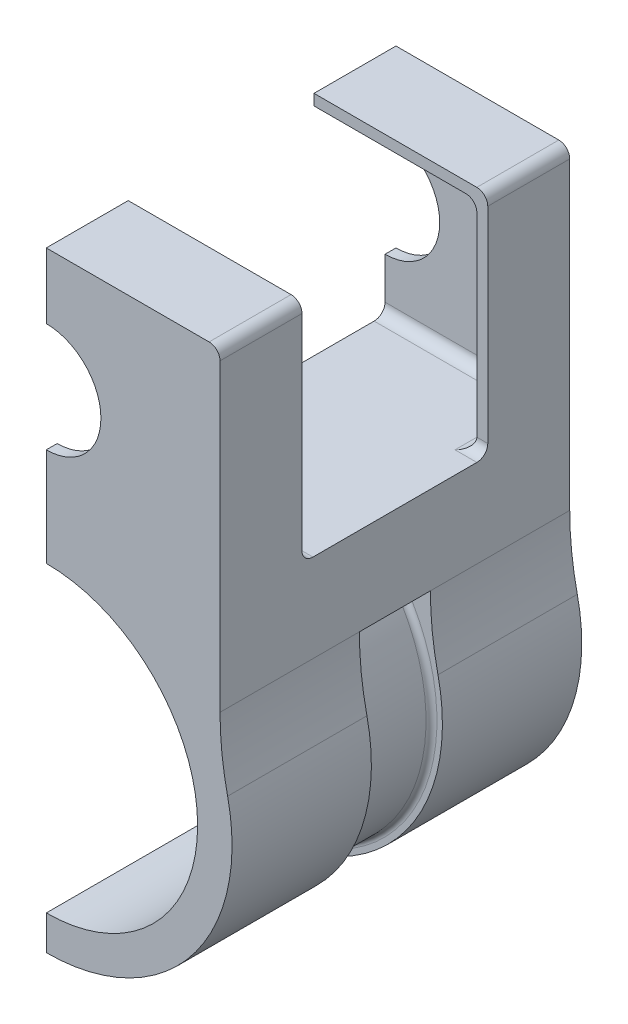
from build123d import *

# Parameters (mm, degrees)
BOSS_EXTRUDE1_DEPTH            = 81.28
SKETCH3_W                      = 76.2
SKETCH3_H                      = 50.292
CUT_EXTRUDE1_DEPTH             = 37.846
SKETCH4_W                      = 40.386
SKETCH4_H                      = 43.18
CUT_EXTRUDE2_DEPTH             = 52.832
FILLET1_R                      = 2.54
FILLET2_R                      = 2.54
FILLET3_R                      = 2.54
FILLET4_R                      = 2.54
SKETCH7_W                      = 16.51
SKETCH7_H                      = 2.54
CUT_EXTRUDE4_REACH             = 54.566
SKETCH8_W                      = 16.51
SKETCH8_H                      = 16.012242806
CUT_EXTRUDE4_DIRECTION_2_DEPTH = 2.54
FILLET5_R                      = 1.27


with BuildPart() as part:
    # Sketch1 → Boss-Extrude1 (new body)
    with BuildSketch(Plane.XY):
        with BuildLine():
            Line((0, 52.959), (0, 58.039))
            ThreePointArc((0, 58.039), (12.7, 70.739), (0, 83.439))
            Line((0, 83.439), (0, 98.679))
            Line((0, 98.679), (40.386, 98.679))
            Line((40.386, 98.679), (40.386, 25.398729968))
            ThreePointArc((40.386, 25.398729968), (40.827682914, 17.344312358), (42.147434783, 9.386487162))
            ThreePointArc((42.147434783, 9.386487162), (33.688432107, -27.011144777), (0, -43.18))
            Line((0, -43.18), (0, -35.179))
            ThreePointArc((0, -35.179), (35.179, 0), (0, 35.179))
            Line((0, 35.179), (0, 52.959))
        make_face()
    extrude(amount=-BOSS_EXTRUDE1_DEPTH)

    # Sketch3 → Cut-Extrude1 (cut)
    with BuildSketch(Plane.ZY):
        with Locations((-40.64, 70.993)):
            Rectangle(SKETCH3_W, SKETCH3_H)
    extrude(amount=-CUT_EXTRUDE1_DEPTH, mode=Mode.SUBTRACT)

    # Sketch4 → Cut-Extrude2 (cut)
    with BuildSketch(Plane(origin=(0, 98.679, 0), x_dir=(1, 0, 0), z_dir=(0, 1, 0))):
        with Locations((20.193, 40.64)):
            Rectangle(SKETCH4_W, SKETCH4_H)
    extrude(amount=-CUT_EXTRUDE2_DEPTH, mode=Mode.SUBTRACT)

    # Fillet1
    fillet1_edges = [part.edges().sort_by_distance(p)[0] for p in [
        (18.923, 45.847, -78.74),
        (18.923, 45.847, -2.54),
        (37.846, 45.847, -10.795),
        (37.846, 45.847, -70.485),
    ]]
    fillet(fillet1_edges, radius=FILLET1_R)

    # Fillet2
    fillet2_edges = [part.edges().sort_by_distance(p)[0] for p in [
        (37.846, 96.139, -70.485),
        (37.846, 96.139, -10.795),
    ]]
    fillet(fillet2_edges, radius=FILLET2_R)

    # Fillet3
    fillet3_edges = [part.edges().sort_by_distance(p)[0] for p in [
        (36.576, 45.847, -19.05),
        (36.576, 45.847, -62.23),
    ]]
    fillet(fillet3_edges, radius=FILLET3_R)

    # Fillet4
    fillet4_edges = [part.edges().sort_by_distance(p)[0] for p in [
        (40.386, 98.679, -71.755),
        (40.386, 98.679, -9.525),
    ]]
    fillet(fillet4_edges, radius=FILLET4_R)

    # Sketch7 → Cut-Revolve2 (revolve, cut)
    with BuildSketch(Plane.ZY):
        with Locations((-40.64, -41.91)):
            Rectangle(SKETCH7_W, SKETCH7_H)
    revolve(axis=Axis((0, 0, -81.28), (0, 0, 1)), mode=Mode.SUBTRACT)

    # Sketch8 → Cut-Extrude4 (cut, up to next)
    with BuildSketch(Plane(origin=(42.147434783, 9.386487162, 0), x_dir=(0, 0, -1), z_dir=(0.976086957, 0.217380435, 0)), mode=Mode.PRIVATE) as cut_extrude4_sk1:
        with Locations((40.64, 8.006121403)):
            Rectangle(SKETCH8_W, SKETCH8_H)
    cut_extrude4_tool1 = extrude(cut_extrude4_sk1.sketch, amount=-CUT_EXTRUDE4_REACH, mode=Mode.PRIVATE) & part.part
    add(cut_extrude4_tool1.solids().sort_by_distance((40.407061, 17.201158, -40.64))[0], mode=Mode.SUBTRACT)

    # Sketch8 → Cut-Extrude4 direction 2 (cut)
    with BuildSketch(Plane(origin=(42.147434783, 9.386487162, 0), x_dir=(0, 0, -1), z_dir=(0.976086957, 0.217380435, 0))):
        with Locations((40.64, 8.006121403)):
            Rectangle(SKETCH8_W, SKETCH8_H)
    extrude(amount=CUT_EXTRUDE4_DIRECTION_2_DEPTH, mode=Mode.SUBTRACT)

    # Fillet5
    fillet5_edges = [part.edges().sort_by_distance(p)[0] for p in [
        (40.64, 0, -48.895),
        (40.64, 0, -32.385),
    ]]
    fillet(fillet5_edges, radius=FILLET5_R)


solid = part.part
